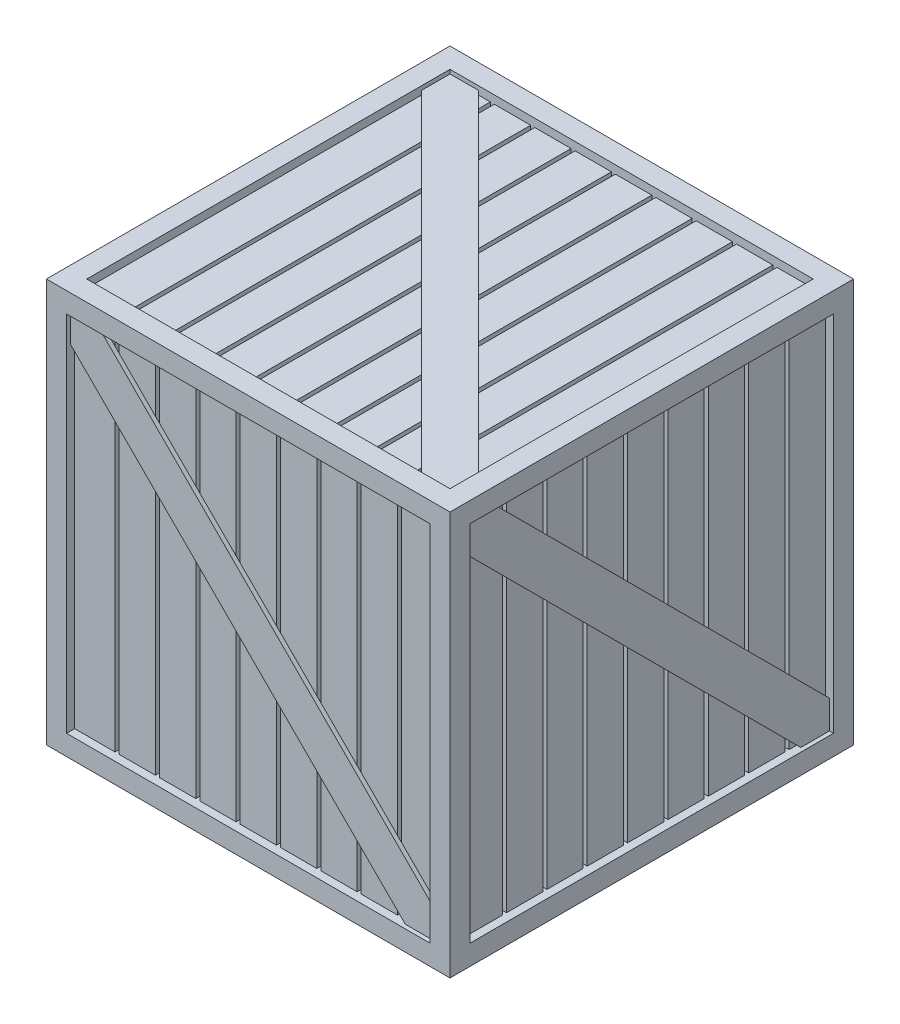
from build123d import *

# Parameters (mm, degrees)
SKETCH1_W           = 100
SKETCH1_H           = 100
BOSS_EXTRUDE1_DEPTH = 50
CUT_EXTRUDE1_DEPTH  = 1
CUT_EXTRUDE2_DEPTH  = 2
SKETCH5_W           = 1
SKETCH5_H           = 90
CUT_EXTRUDE3_DEPTH  = 1
CIRPATTERN1_COUNT   = 4
CIRPATTERN2_COUNT   = 4


with BuildPart() as part:
    # Sketch1 → Boss-Extrude1 (new, symmetric)
    with BuildSketch(Plane(origin=(0, 0, 0), x_dir=(1, 0, 0), z_dir=(0, 1, 0))):
        Rectangle(SKETCH1_W, SKETCH1_H)
    extrude(amount=BOSS_EXTRUDE1_DEPTH, both=True)

    # Sketch3 → Cut-Extrude1 (cut)
    with BuildSketch(Plane.XY.offset(50)):
        Polygon((-45, 45), (-37.928932188, 45), (45, -37.928932188), (45, -45), (37.928932188, -45), (-45, 37.928932188), align=None)
    cut_extrude1 = extrude(amount=-CUT_EXTRUDE1_DEPTH, mode=Mode.SUBTRACT)

    # Sketch4 → Cut-Extrude2 (cut)
    with BuildSketch(Plane.XY.offset(50)):
        Polygon((45, 45), (-37.928932188, 45), (45, -37.928932188), align=None)
        Polygon((37.928932188, -45), (-45, 37.928932188), (-45, -45), align=None)
    cut_extrude2 = extrude(amount=-CUT_EXTRUDE2_DEPTH, mode=Mode.SUBTRACT)

    # Sketch5 → Cut-Extrude3 (cut)
    with BuildSketch(Plane.XY.offset(48)):
        with Locations((-34.5, 0)):
            Rectangle(SKETCH5_W, SKETCH5_H)
        with Locations((-24.5, 0)):
            Rectangle(SKETCH5_W, SKETCH5_H)
        with Locations((-14.5, 0)):
            Rectangle(SKETCH5_W, SKETCH5_H)
        with Locations((-4.5, 0)):
            Rectangle(SKETCH5_W, SKETCH5_H)
        with Locations((5.5, 0)):
            Rectangle(SKETCH5_W, SKETCH5_H)
        with Locations((15.5, 0)):
            Rectangle(SKETCH5_W, SKETCH5_H)
        with Locations((25.5, 0)):
            Rectangle(SKETCH5_W, SKETCH5_H)
        with Locations((35.5, 0)):
            Rectangle(SKETCH5_W, SKETCH5_H)
    cut_extrude3 = extrude(amount=-CUT_EXTRUDE3_DEPTH, mode=Mode.SUBTRACT)

    # CirPattern1: Cut-Extrude1, Cut-Extrude2, Cut-Extrude3 ×4 about axis
    cirpattern1_axis = Axis((-55, 0, 0), (1, 0, 0))
    add([cut_extrude1.rotate(cirpattern1_axis, i * 360 / CIRPATTERN1_COUNT) for i in range(1, CIRPATTERN1_COUNT)], mode=Mode.SUBTRACT)
    add([cut_extrude2.rotate(cirpattern1_axis, i * 360 / CIRPATTERN1_COUNT) for i in range(1, CIRPATTERN1_COUNT)], mode=Mode.SUBTRACT)
    add([cut_extrude3.rotate(cirpattern1_axis, i * 360 / CIRPATTERN1_COUNT) for i in range(1, CIRPATTERN1_COUNT)], mode=Mode.SUBTRACT)

    # CirPattern2: Cut-Extrude1, Cut-Extrude2, Cut-Extrude3 ×4 about axis, 1 skipped
    cirpattern2_axis = Axis((0, -55, 0), (0, 1, 0))
    add([cut_extrude1.rotate(cirpattern2_axis, i * 360 / CIRPATTERN2_COUNT) for i in range(1, CIRPATTERN2_COUNT) if i not in (2,)], mode=Mode.SUBTRACT)
    add([cut_extrude2.rotate(cirpattern2_axis, i * 360 / CIRPATTERN2_COUNT) for i in range(1, CIRPATTERN2_COUNT) if i not in (2,)], mode=Mode.SUBTRACT)
    add([cut_extrude3.rotate(cirpattern2_axis, i * 360 / CIRPATTERN2_COUNT) for i in range(1, CIRPATTERN2_COUNT) if i not in (2,)], mode=Mode.SUBTRACT)


solid = part.part
